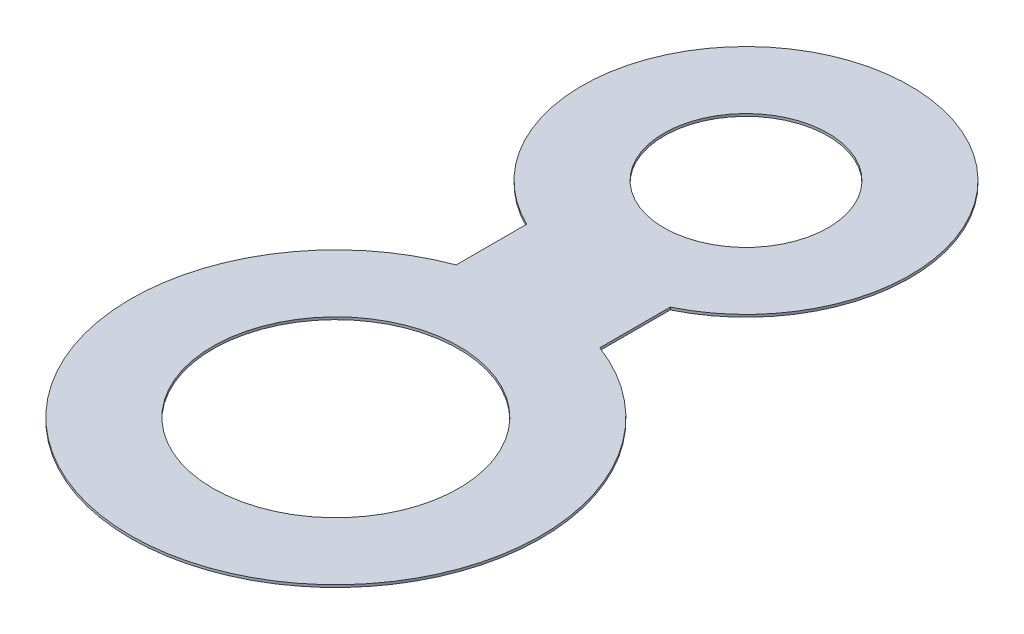
from build123d import *

# Parameters (mm, degrees)
SKETCH1_R           = 20
SKETCH1_R_2         = 10
SKETCH1_R_3         = 25
SKETCH1_R_4         = 15
SKETCH1_W           = 17.5
SKETCH1_H           = 25
BOSS_EXTRUDE1_DEPTH = 0.3


with BuildPart() as part:
    # Sketch1 → Boss-Extrude1 (new body)
    with BuildSketch(Plane(origin=(0, 0, 0), x_dir=(1, 0, 0), z_dir=(0, 1, 0))):
        with Locations((0, 50)):
            Circle(SKETCH1_R)
        with Locations((0, 50)):
            Circle(SKETCH1_R_2, mode=Mode.SUBTRACT)
        Circle(SKETCH1_R_3)
        Circle(SKETCH1_R_4, mode=Mode.SUBTRACT)
        with Locations((0, 27.5)):
            Rectangle(SKETCH1_W, SKETCH1_H)
    extrude(amount=BOSS_EXTRUDE1_DEPTH)


solid = part.part
